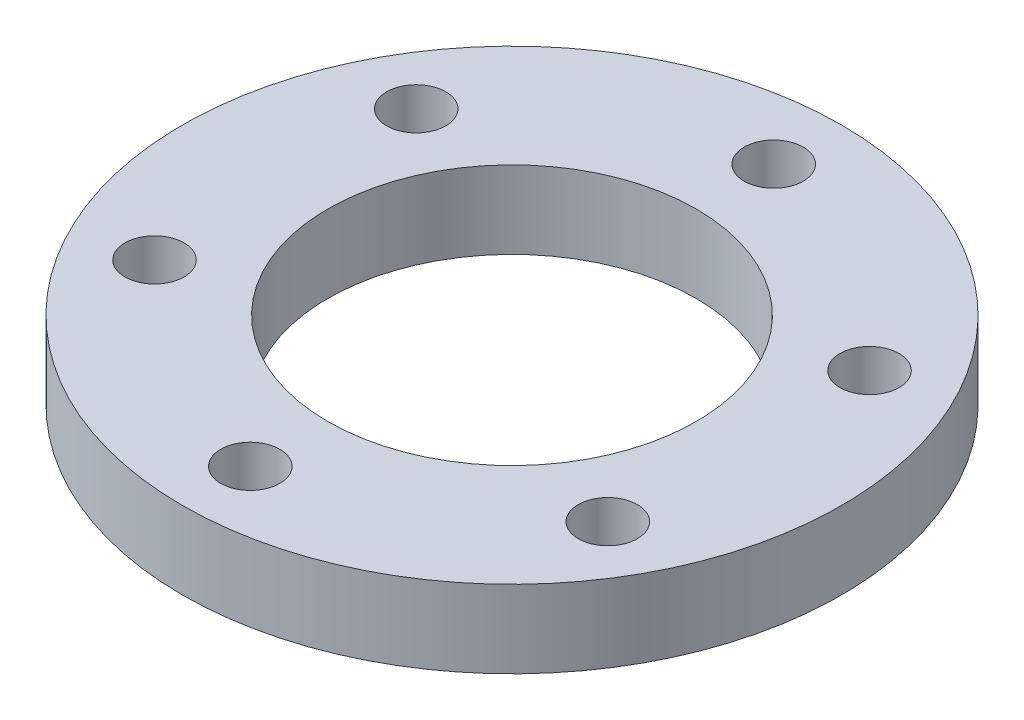
from build123d import *

# Parameters (mm, degrees)
SKETCH_1_R          = 17
SKETCH_1_R_2        = 9.5
EXTRUDE_1_DEPTH     = 4
SKETCH_2_R          = 1.525
CUT_EXTRUDE_1_DEPTH = 100


with BuildPart() as part:
    # 草图1 → 凸台-拉伸1 (new body)
    with BuildSketch(Plane(origin=(0, 0, 0), x_dir=(1, 0, 0), z_dir=(0, 1, 0))):
        Circle(SKETCH_1_R)
        Circle(SKETCH_1_R_2, mode=Mode.SUBTRACT)
    extrude(amount=EXTRUDE_1_DEPTH)

    # 草图2 → 切除-拉伸1 (cut)
    with BuildSketch(Plane(origin=(0, 4, 0), x_dir=(1, 0, 0), z_dir=(0, 1, 0))):
        with Locations((0, 13.5)):
            Circle(SKETCH_2_R)
        with Locations((11.691342951, 6.75)):
            Circle(SKETCH_2_R)
        with Locations((11.691342951, -6.75)):
            Circle(SKETCH_2_R)
        with Locations((0, -13.5)):
            Circle(SKETCH_2_R)
        with Locations((-11.691342951, -6.75)):
            Circle(SKETCH_2_R)
        with Locations((-11.691342951, 6.75)):
            Circle(SKETCH_2_R)
    extrude(amount=-CUT_EXTRUDE_1_DEPTH, mode=Mode.SUBTRACT)


solid = part.part
